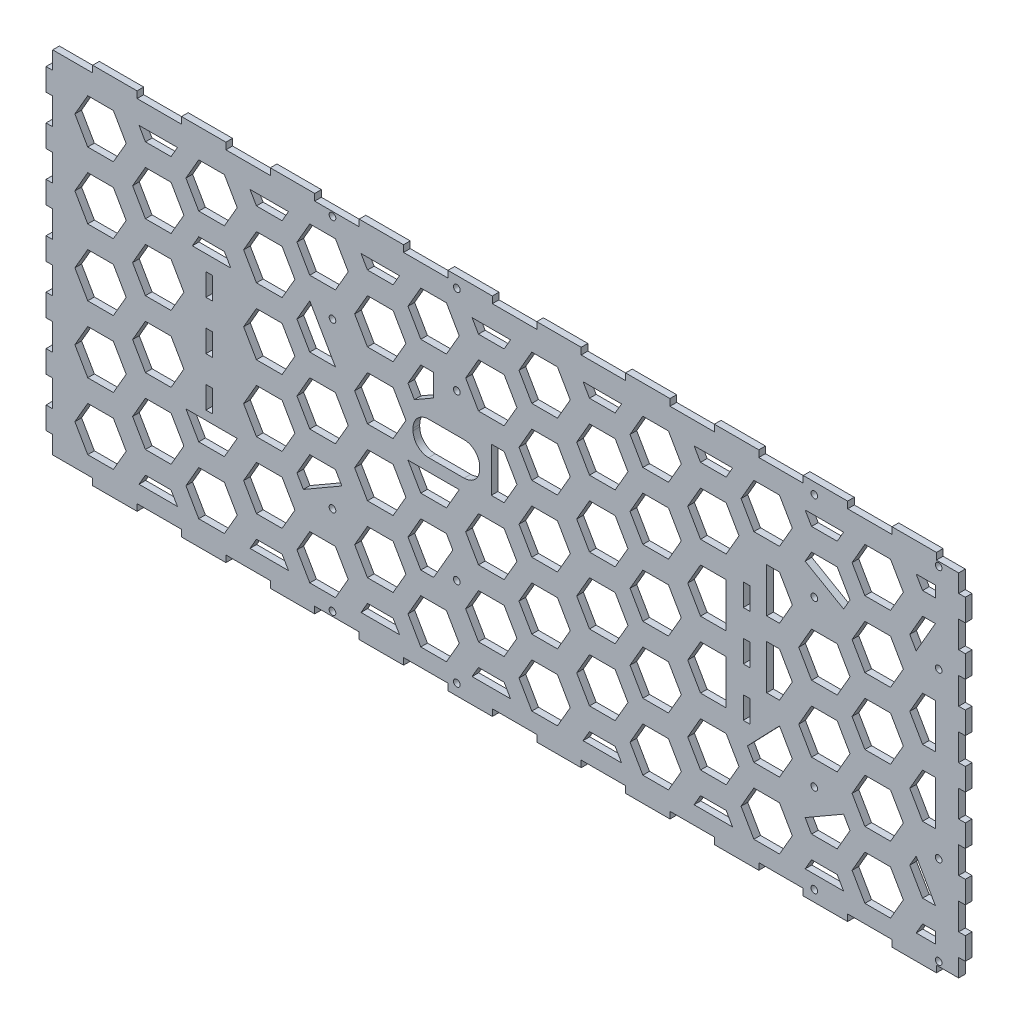
from build123d import *

# Parameters (mm, degrees)
SKETCH1_W           = 414
SKETCH1_H           = 164
BOSS_EXTRUDE1_DEPTH = 3
SKETCH2_W           = 3
SKETCH2_H           = 11
SKETCH2_H_2         = 12
CUT_EXTRUDE1_DEPTH  = 3
CUT_EXTRUDE2_DEPTH  = 3
SKETCH4_R           = 1.5
SKETCH4_W           = 3
SKETCH4_H           = 10
CUT_EXTRUDE3_DEPTH  = 10
CUT_EXTRUDE4_DEPTH  = 10
CUT_EXTRUDE5_DEPTH  = 4


with BuildPart() as part:
    # Sketch1 → Boss-Extrude1 (new body)
    with BuildSketch(Plane.XY.offset(152)):
        Rectangle(SKETCH1_W, SKETCH1_H)
    extrude(amount=BOSS_EXTRUDE1_DEPTH)

    # Sketch2 → Cut-Extrude1 (cut)
    with BuildSketch(Plane.ZY.offset(207)):
        with Locations((153.5, -76.5)):
            Rectangle(SKETCH2_W, SKETCH2_H)
        with Locations((153.5, -55)):
            Rectangle(SKETCH2_W, SKETCH2_H_2)
        with Locations((153.5, -33)):
            Rectangle(SKETCH2_W, SKETCH2_H_2)
        with Locations((153.5, -11)):
            Rectangle(SKETCH2_W, SKETCH2_H_2)
        with Locations((153.5, 11)):
            Rectangle(SKETCH2_W, SKETCH2_H_2)
        with Locations((153.5, 33)):
            Rectangle(SKETCH2_W, SKETCH2_H_2)
        with Locations((153.5, 55)):
            Rectangle(SKETCH2_W, SKETCH2_H_2)
        with Locations((153.5, 76.5)):
            Rectangle(SKETCH2_W, SKETCH2_H)
    cut_extrude1 = extrude(amount=-CUT_EXTRUDE1_DEPTH, mode=Mode.SUBTRACT)

    # Mirror1: Cut-Extrude1 across plane
    add(cut_extrude1.mirror(Plane(origin=(0, 0, 0), x_dir=(0, 0, 1), z_dir=(1, 0, 0))), mode=Mode.SUBTRACT)

    # Sketch3 → Cut-Extrude2 (cut)
    with BuildSketch(Plane(origin=(0, 82, 0), x_dir=(1, 0, 0), z_dir=(0, 1, 0))):
        Polygon((174, -152), (194, -152), (194, -155), (204, -155), (204, -145), (207, -145), (207, -133), (204, -133), (204, -123), (207, -123), (207, -111), (204, -111), (204, -101), (207, -101), (207, -89), (204, -89), (204, -79), (207, -79), (207, -67), (204, -67), (204, -57), (207, -57), (207, -45), (204, -45), (204, -35), (207, -35), (207, -23), (204, -23), (204, -16), (-204, -16), (-204, -23), (-207, -23), (-207, -35), (-204, -35), (-204, -45), (-207, -45), (-207, -57), (-204, -57), (-204, -67), (-207, -67), (-207, -79), (-204, -79), (-204, -89), (-207, -89), (-207, -101), (-204, -101), (-204, -111), (-207, -111), (-207, -123), (-204, -123), (-204, -133), (-207, -133), (-207, -145), (-204, -145), (-204, -155), (-186, -155), (-186, -152), (-166, -152), (-166, -155), (-146, -155), (-146, -152), (-126, -152), (-126, -155), (-106, -155), (-106, -152), (-86, -152), (-86, -155), (-66, -155), (-66, -152), (-46, -152), (-46, -155), (-26, -155), (-26, -152), (-6, -152), (-6, -155), (14, -155), (14, -152), (34, -152), (34, -155), (54, -155), (54, -152), (74, -152), (74, -155), (94, -155), (94, -152), (114, -152), (114, -155), (134, -155), (134, -152), (154, -152), (154, -155), (174, -155), align=None)
    cut_extrude2 = extrude(amount=-CUT_EXTRUDE2_DEPTH, mode=Mode.SUBTRACT)

    # Mirror2: Cut-Extrude2 across plane
    add(cut_extrude2.mirror(Plane.ZX), mode=Mode.SUBTRACT)

    # Sketch4 → Cut-Extrude3 (cut)
    with BuildSketch(Plane.XY.offset(155)):
        with Locations((139, 37)):
            Circle(SKETCH4_R)
        with Locations((195, 37)):
            Circle(SKETCH4_R)
        with Locations((195, 77)):
            Circle(SKETCH4_R)
        with Locations((139, 77)):
            Circle(SKETCH4_R)
        with Locations((-78, 77)):
            Circle(SKETCH4_R)
        with Locations((-22, 77)):
            Circle(SKETCH4_R)
        with Locations((-78, 37)):
            Circle(SKETCH4_R)
        with Locations((-22, 37)):
            Circle(SKETCH4_R)
        with Locations((139, -77)):
            Circle(SKETCH4_R)
        with Locations((195, -77)):
            Circle(SKETCH4_R)
        with Locations((195, -37)):
            Circle(SKETCH4_R)
        with Locations((139, -37)):
            Circle(SKETCH4_R)
        with Locations((-22, -37)):
            Circle(SKETCH4_R)
        with Locations((-78, -37)):
            Circle(SKETCH4_R)
        with Locations((-22, -77)):
            Circle(SKETCH4_R)
        with Locations((-78, -77)):
            Circle(SKETCH4_R)
        with Locations((-133.5, 22)):
            Rectangle(SKETCH4_W, SKETCH4_H)
        with Locations((-133.5, 0)):
            Rectangle(SKETCH4_W, SKETCH4_H)
        with Locations((-133.5, -22)):
            Rectangle(SKETCH4_W, SKETCH4_H)
        with Locations((108.5, 22)):
            Rectangle(SKETCH4_W, SKETCH4_H)
        with Locations((108.5, 0)):
            Rectangle(SKETCH4_W, SKETCH4_H)
        with Locations((108.5, -22)):
            Rectangle(SKETCH4_W, SKETCH4_H)
    extrude(amount=-CUT_EXTRUDE3_DEPTH, mode=Mode.SUBTRACT)

    # Sketch5 → Cut-Extrude4 (cut)
    with BuildSketch(Plane.XY.offset(155)):
        with BuildLine():
            Line((-34.7, 4.6), (-18.7, 4.6))
            ThreePointArc((-18.7, 4.6), (-13.750252532, 6.650252532), (-11.7, 11.6))
            Line((-11.7, 11.6), (-11.7, 12.6))
            ThreePointArc((-11.7, 12.6), (-13.750252532, 17.549747468), (-18.7, 19.6))
            Line((-18.7, 19.6), (-34.7, 19.6))
            ThreePointArc((-34.7, 19.6), (-39.649747468, 17.549747468), (-41.7, 12.6))
            Line((-41.7, 12.6), (-41.7, 11.6))
            ThreePointArc((-41.7, 11.6), (-39.649747468, 6.650252532), (-34.7, 4.6))
        make_face()
    extrude(amount=-CUT_EXTRUDE4_DEPTH, mode=Mode.SUBTRACT)

    # Sketch6 → Cut-Extrude5 (cut, through all)
    with BuildSketch(Plane.XY.offset(155)):
        Polygon((-170.905989232, 59), (-176.679491924, 69), (-188.226497308, 69), (-194, 59), (-188.226497308, 49), (-176.679491924, 49), align=None)
        Polygon((-144.925227119, 44), (-150.698729811, 54), (-162.245735195, 54), (-168.019237886, 44), (-162.245735195, 34), (-150.698729811, 34), align=None)
        Polygon((-120.905989232, 59), (-126.679491924, 69), (-138.226497308, 69), (-144, 59), (-138.226497308, 49), (-126.679491924, 49), align=None)
        Polygon((-94.925227119, 44), (-100.698729811, 54), (-112.245735195, 54), (-118.019237886, 44), (-112.245735195, 34), (-100.698729811, 34), align=None)
        Polygon((-70.905989232, 59), (-76.679491924, 69), (-88.226497308, 69), (-94, 59), (-88.226497308, 49), (-76.679491924, 49), align=None)
        Polygon((-44.925227119, 44), (-50.698729811, 54), (-62.245735195, 54), (-68.019237886, 44), (-62.245735195, 34), (-50.698729811, 34), align=None)
        Polygon((-20.905989232, 59), (-26.679491924, 69), (-38.226497308, 69), (-44, 59), (-38.226497308, 49), (-26.679491924, 49), align=None)
        Polygon((5.074772881, 44), (-0.698729811, 54), (-12.245735195, 54), (-18.019237886, 44), (-12.245735195, 34), (-0.698729811, 34), align=None)
        Polygon((29.094010768, 59), (23.320508076, 69), (11.773502692, 69), (6, 59), (11.773502692, 49), (23.320508076, 49), align=None)
        Polygon((55.074772881, 44), (49.301270189, 54), (37.754264805, 54), (31.980762114, 44), (37.754264805, 34), (49.301270189, 34), align=None)
        Polygon((79.094010768, 59), (73.320508076, 69), (61.773502692, 69), (56, 59), (61.773502692, 49), (73.320508076, 49), align=None)
        Polygon((105.074772881, 44), (99.301270189, 54), (87.754264805, 54), (81.980762114, 44), (87.754264805, 34), (99.301270189, 34), align=None)
        Polygon((129.094010768, 59), (123.320508076, 69), (111.773502692, 69), (106, 59), (111.773502692, 49), (123.320508076, 49), align=None)
        Polygon((155.074772881, 44), (149.301270189, 54), (137.754264805, 54), (134.867513459, 49), (152.188021535, 39), align=None)
        Polygon((179.094010768, 59), (173.320508076, 69), (161.773502692, 69), (156, 59), (161.773502692, 49), (173.320508076, 49), align=None)
        Polygon((193.527767497, 54), (187.754264805, 54), (181.980762114, 44), (184.867513459, 39), align=None)
        Polygon((-123.792740578, 34), (-126.679491924, 39), (-138.226497308, 39), (-141.113248654, 34), align=None)
        Polygon((-94.925227119, 14), (-100.698729811, 24), (-112.245735195, 24), (-118.019237886, 14), (-112.245735195, 4), (-100.698729811, 4), align=None)
        Polygon((-88.226497308, 39), (-94, 29), (-88.226497308, 19), (-76.679491924, 19), align=None)
        Polygon((-44.925227119, 14), (-50.698729811, 24), (-62.245735195, 24), (-68.019237886, 14), (-62.245735195, 4), (-50.698729811, 4), align=None)
        Polygon((-32.452994616, 39), (-38.226497308, 39), (-44, 29), (-41.113248654, 24), (-32.452994616, 29), align=None)
        Polygon((5.074772881, 14), (-0.698729811, 24), (-6.472232503, 24), (-6.472232503, 4), (-0.698729811, 4), align=None)
        Polygon((29.094010768, 29), (23.320508076, 39), (11.773502692, 39), (6, 29), (11.773502692, 19), (23.320508076, 19), align=None)
        Polygon((55.074772881, 14), (49.301270189, 24), (37.754264805, 24), (31.980762114, 14), (37.754264805, 4), (49.301270189, 4), align=None)
        Polygon((79.094010768, 29), (73.320508076, 39), (61.773502692, 39), (56, 29), (61.773502692, 19), (73.320508076, 19), align=None)
        Polygon((99.301270189, 24), (87.754264805, 24), (81.980762114, 14), (87.754264805, 4), (99.301270189, 4), align=None)
        Polygon((129.094010768, 29), (123.320508076, 39), (117.547005384, 39), (117.547005384, 19), (123.320508076, 19), align=None)
        Polygon((155.074772881, 14), (149.301270189, 24), (137.754264805, 24), (131.980762114, 14), (137.754264805, 4), (149.301270189, 4), align=None)
        Polygon((179.094010768, 29), (173.320508076, 39), (161.773502692, 39), (156, 29), (161.773502692, 19), (173.320508076, 19), align=None)
        Polygon((193.527767497, 24), (187.754264805, 24), (181.980762114, 14), (187.754264805, 4), (193.527767497, 4), align=None)
        Polygon((-94.925227119, -16), (-100.698729811, -6), (-112.245735195, -6), (-118.019237886, -16), (-112.245735195, -26), (-100.698729811, -26), align=None)
        Polygon((-70.905989232, -1), (-76.679491924, 9), (-88.226497308, 9), (-94, -1), (-88.226497308, -11), (-76.679491924, -11), align=None)
        Polygon((-44.925227119, -16), (-50.698729811, -6), (-62.245735195, -6), (-68.019237886, -16), (-62.245735195, -26), (-50.698729811, -26), align=None)
        Polygon((-44, -1), (-38.226497308, -11), (-26.679491924, -11), (-20.905989232, -1), align=None)
        Polygon((5.074772881, -16), (-0.698729811, -6), (-12.245735195, -6), (-18.019237886, -16), (-12.245735195, -26), (-0.698729811, -26), align=None)
        Polygon((29.094010768, -1), (23.320508076, 9), (11.773502692, 9), (6, -1), (11.773502692, -11), (23.320508076, -11), align=None)
        Polygon((55.074772881, -16), (49.301270189, -6), (37.754264805, -6), (31.980762114, -16), (37.754264805, -26), (49.301270189, -26), align=None)
        Polygon((79.094010768, -1), (73.320508076, 9), (61.773502692, 9), (56, -1), (61.773502692, -11), (73.320508076, -11), align=None)
        Polygon((99.301270189, -6), (87.754264805, -6), (81.980762114, -16), (87.754264805, -26), (99.301270189, -26), align=None)
        Polygon((129.094010768, -1), (123.320508076, 9), (117.547005384, 9), (117.547005384, -11), (123.320508076, -11), align=None)
        Polygon((155.074772881, -16), (149.301270189, -6), (137.754264805, -6), (131.980762114, -16), (137.754264805, -26), (149.301270189, -26), align=None)
        Polygon((179.094010768, -1), (173.320508076, 9), (161.773502692, 9), (156, -1), (161.773502692, -11), (173.320508076, -11), align=None)
        Polygon((193.527767497, -6), (187.754264805, -6), (181.980762114, -16), (187.754264805, -26), (193.527767497, -26), align=None)
        Polygon((-144, -31), (-138.226497308, -41), (-126.679491924, -41), (-120.905989232, -31), align=None)
        Polygon((-94.925227119, -46), (-100.698729811, -36), (-112.245735195, -36), (-118.019237886, -46), (-112.245735195, -56), (-100.698729811, -56), align=None)
        Polygon((-73.792740578, -26), (-76.679491924, -21), (-88.226497308, -21), (-94, -31), (-91.113248654, -36), align=None)
        Polygon((-44.925227119, -46), (-50.698729811, -36), (-62.245735195, -36), (-68.019237886, -46), (-62.245735195, -56), (-50.698729811, -56), align=None)
        Polygon((-23.792740578, -26), (-26.679491924, -21), (-38.226497308, -21), (-44, -31), (-38.226497308, -41), (-32.452994616, -41), align=None)
        Polygon((5.074772881, -46), (-0.698729811, -36), (-12.245735195, -36), (-18.019237886, -46), (-12.245735195, -56), (-0.698729811, -56), align=None)
        Polygon((29.094010768, -31), (23.320508076, -21), (11.773502692, -21), (6, -31), (11.773502692, -41), (23.320508076, -41), align=None)
        Polygon((55.074772881, -46), (49.301270189, -36), (37.754264805, -36), (31.980762114, -46), (37.754264805, -56), (49.301270189, -56), align=None)
        Polygon((79.094010768, -31), (73.320508076, -21), (61.773502692, -21), (56, -31), (61.773502692, -41), (73.320508076, -41), align=None)
        Polygon((105.074772881, -46), (99.301270189, -36), (87.754264805, -36), (81.980762114, -46), (87.754264805, -56), (99.301270189, -56), align=None)
        Polygon((129.094010768, -31), (123.320508076, -21), (108.886751346, -36), (111.773502692, -41), (123.320508076, -41), align=None)
        Polygon((155.074772881, -46), (152.188021535, -41), (134.867513459, -51), (137.754264805, -56), (149.301270189, -56), align=None)
        Polygon((179.094010768, -31), (173.320508076, -21), (161.773502692, -21), (156, -31), (161.773502692, -41), (173.320508076, -41), align=None)
        Polygon((184.867513459, -41), (181.980762114, -46), (187.754264805, -56), (193.527767497, -56), align=None)
        Polygon((-120.905989232, -61), (-126.679491924, -51), (-138.226497308, -51), (-144, -61), (-138.226497308, -71), (-126.679491924, -71), align=None)
        Polygon((-70.905989232, -61), (-76.679491924, -51), (-88.226497308, -51), (-94, -61), (-88.226497308, -71), (-76.679491924, -71), align=None)
        Polygon((-20.905989232, -61), (-26.679491924, -51), (-38.226497308, -51), (-44, -61), (-38.226497308, -71), (-26.679491924, -71), align=None)
        Polygon((29.094010768, -61), (23.320508076, -51), (11.773502692, -51), (6, -61), (11.773502692, -71), (23.320508076, -71), align=None)
        Polygon((79.094010768, -61), (73.320508076, -51), (61.773502692, -51), (56, -61), (61.773502692, -71), (73.320508076, -71), align=None)
        Polygon((129.094010768, -61), (123.320508076, -51), (111.773502692, -51), (106, -61), (111.773502692, -71), (123.320508076, -71), align=None)
        Polygon((179.094010768, -61), (173.320508076, -51), (161.773502692, -51), (156, -61), (161.773502692, -71), (173.320508076, -71), align=None)
        Polygon((-170.905989232, 29), (-176.679491924, 39), (-188.226497308, 39), (-194, 29), (-188.226497308, 19), (-176.679491924, 19), align=None)
        Polygon((-144.925227119, 14), (-150.698729811, 24), (-162.245735195, 24), (-168.019237886, 14), (-162.245735195, 4), (-150.698729811, 4), align=None)
        Polygon((-170.905989232, -1), (-176.679491924, 9), (-188.226497308, 9), (-194, -1), (-188.226497308, -11), (-176.679491924, -11), align=None)
        Polygon((-144.925227119, -16), (-150.698729811, -6), (-162.245735195, -6), (-168.019237886, -16), (-162.245735195, -26), (-150.698729811, -26), align=None)
        Polygon((-170.905989232, -31), (-176.679491924, -21), (-188.226497308, -21), (-194, -31), (-188.226497308, -41), (-176.679491924, -41), align=None)
        Polygon((-144.925227119, -46), (-150.698729811, -36), (-162.245735195, -36), (-168.019237886, -46), (-162.245735195, -56), (-150.698729811, -56), align=None)
        Polygon((-170.905989232, -61), (-176.679491924, -51), (-188.226497308, -51), (-194, -61), (-188.226497308, -71), (-176.679491924, -71), align=None)
        Polygon((-165.132486541, 69), (-162.245735195, 64), (-150.698729811, 64), (-147.811978465, 69), align=None)
        Polygon((-100.698729811, 64), (-97.811978465, 69), (-115.132486541, 69), (-112.245735195, 64), align=None)
        Polygon((-50.698729811, 64), (-47.811978465, 69), (-65.132486541, 69), (-62.245735195, 64), align=None)
        Polygon((-0.698729811, 64), (2.188021535, 69), (-15.132486541, 69), (-12.245735195, 64), align=None)
        Polygon((49.301270189, 64), (52.188021535, 69), (34.867513459, 69), (37.754264805, 64), align=None)
        Polygon((99.301270189, 64), (102.188021535, 69), (84.867513459, 69), (87.754264805, 64), align=None)
        Polygon((149.301270189, 64), (152.188021535, 69), (134.867513459, 69), (137.754264805, 64), align=None)
        Polygon((184.867513459, 69), (193.527767497, 69), (193.527767497, 64), (187.754264805, 64), align=None)
        Polygon((-147.811978465, -71), (-150.698729811, -66), (-162.245735195, -66), (-165.132486541, -71), align=None)
        Polygon((-97.811978465, -71), (-100.698729811, -66), (-112.245735195, -66), (-115.132486541, -71), align=None)
        Polygon((-47.811978465, -71), (-50.698729811, -66), (-62.245735195, -66), (-65.132486541, -71), align=None)
        Polygon((2.188021535, -71), (-0.698729811, -66), (-12.245735195, -66), (-15.132486541, -71), align=None)
        Polygon((52.188021535, -71), (49.301270189, -66), (37.754264805, -66), (34.867513459, -71), align=None)
        Polygon((102.188021535, -71), (99.301270189, -66), (87.754264805, -66), (84.867513459, -71), align=None)
        Polygon((152.188021535, -71), (149.301270189, -66), (137.754264805, -66), (134.867513459, -71), align=None)
        Polygon((193.527767497, -66), (187.754264805, -66), (184.867513459, -71), (193.527767497, -71), align=None)
    extrude(amount=-CUT_EXTRUDE5_DEPTH, mode=Mode.SUBTRACT)


solid = part.part
